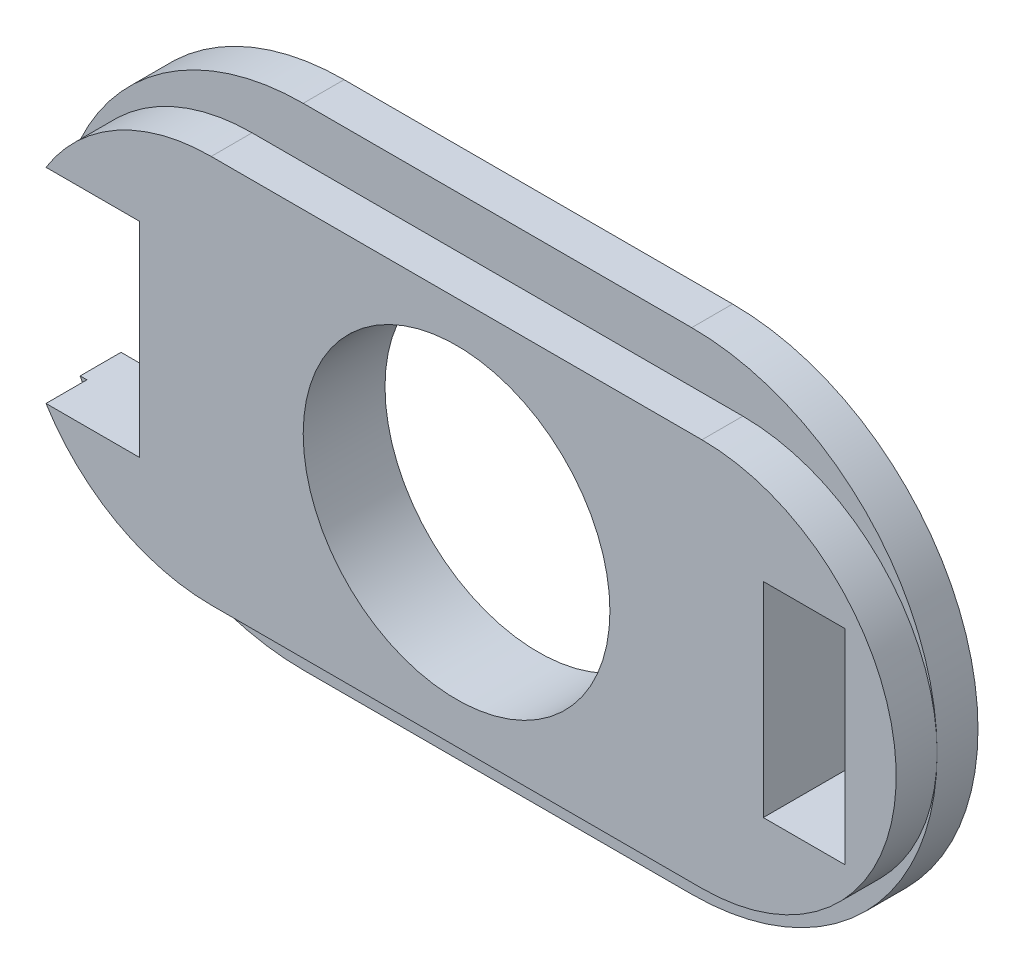
from build123d import *

# Parameters (mm, degrees)
EXTRUSION1_DEPTH        = 2
EXTRUSION4_DEPTH        = 2
ESQUISSE3_R             = 7.5
ESQUISSE3_W             = 4
ESQUISSE3_H             = 10
ESQUISSE3_W_2           = 6
ENL_V_MAT_EXTRU_1_DEPTH = 5


with BuildPart() as part:
    # Esquisse1 → Extrusion1 (new body)
    with BuildSketch(Plane.XY):
        with BuildLine():
            Line((-57.049073, 33.907042), (-38.049073, 33.907042))
            ThreePointArc((-38.049073, 33.907042), (-26.049073, 21.907042), (-38.049073, 9.907042))
            Line((-38.049073, 9.907042), (-57.049073, 9.907042))
            ThreePointArc((-57.049073, 9.907042), (-69.049073, 21.907042), (-57.049073, 33.907042))
        make_face()
    extrude(amount=EXTRUSION1_DEPTH)

    # Esquisse2 → Extrusion4 (add)
    with BuildSketch(Plane.XY.offset(2)):
        with BuildLine():
            Line((-59.549073, 31.407042), (-35.549073, 31.407042))
            ThreePointArc((-35.549073, 31.407042), (-26.049073, 21.907042), (-35.549073, 12.407042))
            Line((-35.549073, 12.407042), (-59.549073, 12.407042))
            ThreePointArc((-59.549073, 12.407042), (-69.049073, 21.907042), (-59.549073, 31.407042))
        make_face()
    extrude(amount=EXTRUSION4_DEPTH)

    # Esquisse3 → Enlèv. mat.-Extru.1 (cut, through all)
    with BuildSketch(Plane.XY.offset(4)):
        with Locations((-47.549073, 21.907042)):
            Circle(ESQUISSE3_R)
        with Locations((-30.549073, 21.907042)):
            Rectangle(ESQUISSE3_W, ESQUISSE3_H)
        with Locations((-66.049073, 21.907042)):
            Rectangle(ESQUISSE3_W_2, ESQUISSE3_H)
    extrude(amount=-ENL_V_MAT_EXTRU_1_DEPTH, mode=Mode.SUBTRACT)


solid = part.part
